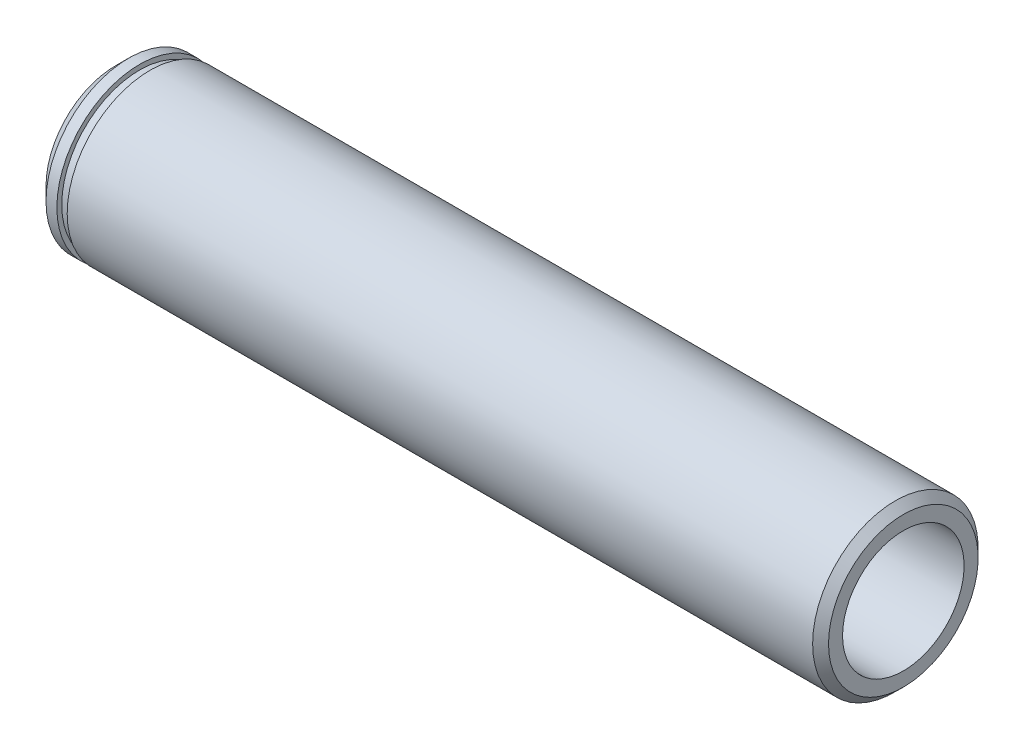
from build123d import *


with BuildPart() as part:
    # Sketch1 → Revolve1 (revolve)
    with BuildSketch(Plane(origin=(0, 0, 0), x_dir=(-1, 0, 0), z_dir=(0, 0, -1))):
        Polygon((0, 5.9944), (0, 6.6675), (-1.27, 7.9375), (-2.3114, 7.9375), (-2.3114, 7.4676), (-3.302, 7.4676), (-3.302, 7.9375), (-74.803, 7.9375), (-75.565, 7.1755), (-75.565, 5.8293), (-8.89, 5.8293), (-8.89, 5.9944), align=None)
    revolve(axis=Axis((75.565, 0, 0), (-1, 0, 0)))


solid = part.part
